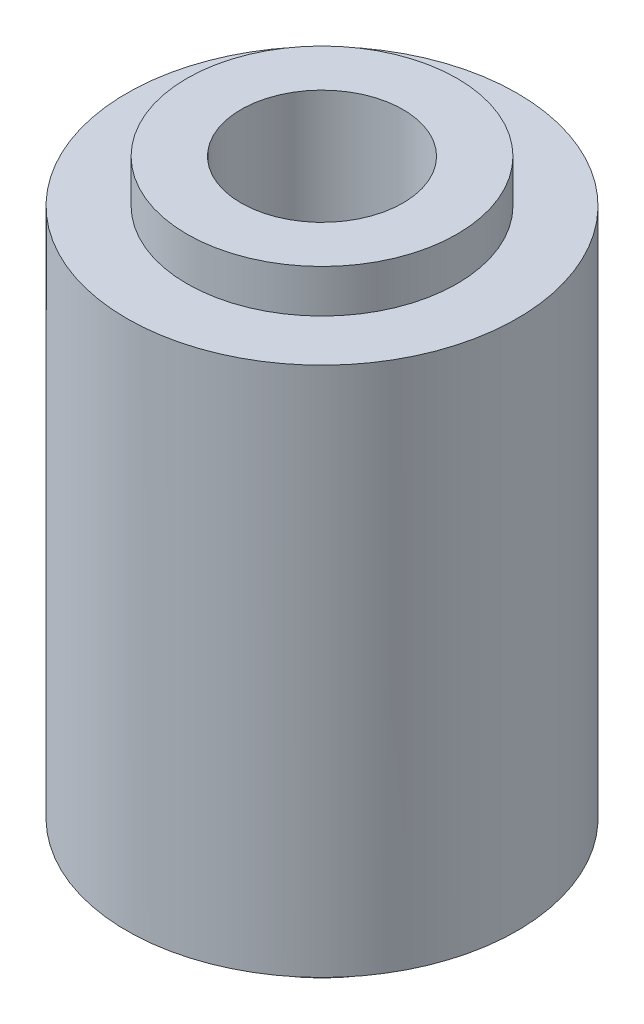
from build123d import *

# Parameters (mm, degrees)
SKETCH2_R                = 3.9751
BOSS_EXTRUDE1_DEPTH      = 5.6
M4X0_7_TAPPED_HOLE1_D    = 3.3
SKETCH7_R                = 2.75
SKETCH7_R_2              = 1.65
BOSS_EXTRUDE2_DEPTH      = 0.675
BOSS_EXTRUDE2_DEPTH_BACK = 11.875
SKETCH9_R                = 3.9751
SKETCH9_R_2              = 2.75
CUT_EXTRUDE1_DEPTH       = 0.2
SKETCH10_R               = 3.9751
SKETCH10_R_2             = 2.75
CUT_EXTRUDE3_DEPTH       = 0.2


with BuildPart() as part:
    # Sketch2 → Boss-Extrude1 (new, symmetric)
    with BuildSketch(Plane(origin=(0, 0, 0), x_dir=(1, 0, 0), z_dir=(0, 1, 0))):
        with Locations(Location((0, 0, 0), (0, 0, 270))):
            Circle(SKETCH2_R)
    extrude(amount=BOSS_EXTRUDE1_DEPTH, both=True)

    # M4x0.7 Tapped Hole1 (through all)
    with Locations(Plane(origin=(0, 5.6, 0), x_dir=(1, 0, 0), z_dir=(0, 1, 0))):
        with Locations((0, 0)):
            Hole(M4X0_7_TAPPED_HOLE1_D / 2)

    # Sketch7 → Boss-Extrude2 (add, two sides)
    with BuildSketch(Plane(origin=(0, 5.6, 0), x_dir=(1, 0, 0), z_dir=(0, 1, 0))) as boss_extrude2_sk:
        with Locations(Location((0, 0, 0), (0, 0, 270))):
            Circle(SKETCH7_R)
        with Locations(Location((0, 0, 0), (0, 0, 270))):
            Circle(SKETCH7_R_2, mode=Mode.SUBTRACT)
    extrude(amount=BOSS_EXTRUDE2_DEPTH)
    extrude(boss_extrude2_sk.sketch, amount=-BOSS_EXTRUDE2_DEPTH_BACK)

    # Sketch9 → Cut-Extrude1 (cut)
    with BuildSketch(Plane(origin=(0, 5.6, 0), x_dir=(1, 0, 0), z_dir=(0, 1, 0))):
        with Locations(Location((0, 0, 0), (0, 0, 270))):
            Circle(SKETCH9_R)
        with Locations(Location((0, 0, 0), (0, 0, 270))):
            Circle(SKETCH9_R_2, mode=Mode.SUBTRACT)
    extrude(amount=-CUT_EXTRUDE1_DEPTH, mode=Mode.SUBTRACT)

    # Sketch10 → Cut-Extrude3 (cut)
    with BuildSketch(Plane.XZ.offset(5.6)):
        with Locations(Location((0, 0, 0), (0, 0, 270))):
            Circle(SKETCH10_R)
        with Locations(Location((0, 0, 0), (0, 0, 90))):
            Circle(SKETCH10_R_2, mode=Mode.SUBTRACT)
    extrude(amount=-CUT_EXTRUDE3_DEPTH, mode=Mode.SUBTRACT)


solid = part.part
